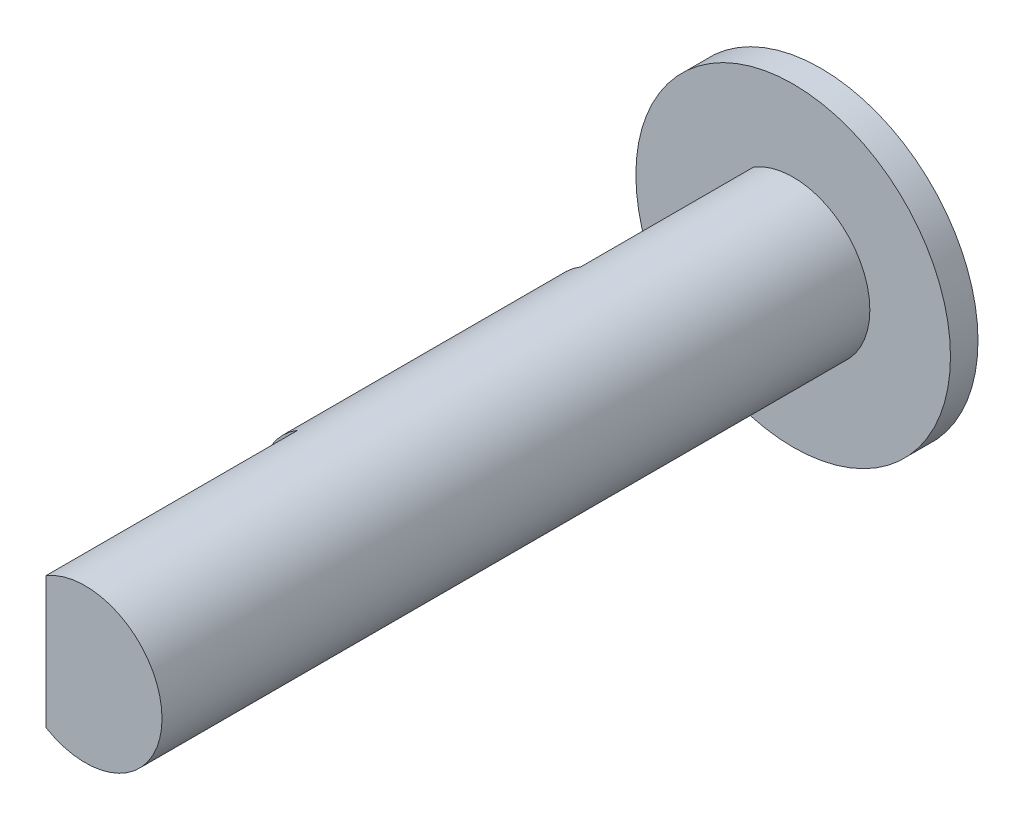
from build123d import *

# Parameters (mm, degrees)
SKETCH2_R           = 1.95
BOSS_EXTRUDE1_DEPTH = 9
CUT_EXTRUDE1_DEPTH  = 4.4
SKETCH5_R           = 4
BOSS_EXTRUDE2_DEPTH = 0.7
CUT_EXTRUDE2_DEPTH  = 6.4


with BuildPart() as part:
    # Sketch2 → Boss-Extrude1 (new body, symmetric)
    with BuildSketch(Plane.XY):
        Circle(SKETCH2_R)
    extrude(amount=BOSS_EXTRUDE1_DEPTH, both=True)

    # Sketch4 → Cut-Extrude1 (cut)
    with BuildSketch(Plane(origin=(0, 0, -9), x_dir=(-1, 0, 0), z_dir=(0, 0, -1))):
        with BuildLine():
            Line((1, 1.674066904), (1, -1.674066904))
            ThreePointArc((1, -1.674066904), (1.95, 0), (1, 1.674066904))
        make_face()
    extrude(amount=-CUT_EXTRUDE1_DEPTH, mode=Mode.SUBTRACT)

    # Sketch5 → Boss-Extrude2 (add)
    with BuildSketch(Plane(origin=(0, 0, -9), x_dir=(-1, 0, 0), z_dir=(0, 0, -1))):
        Circle(SKETCH5_R)
    extrude(amount=BOSS_EXTRUDE2_DEPTH)

    # Sketch9 → Cut-Extrude2 (cut)
    with BuildSketch(Plane.XY.offset(9)):
        with BuildLine():
            Line((-1, 1.674066904), (-1, -1.674066904))
            ThreePointArc((-1, -1.674066904), (-1.95, 0), (-1, 1.674066904))
        make_face()
    extrude(amount=-CUT_EXTRUDE2_DEPTH, mode=Mode.SUBTRACT)


solid = part.part
